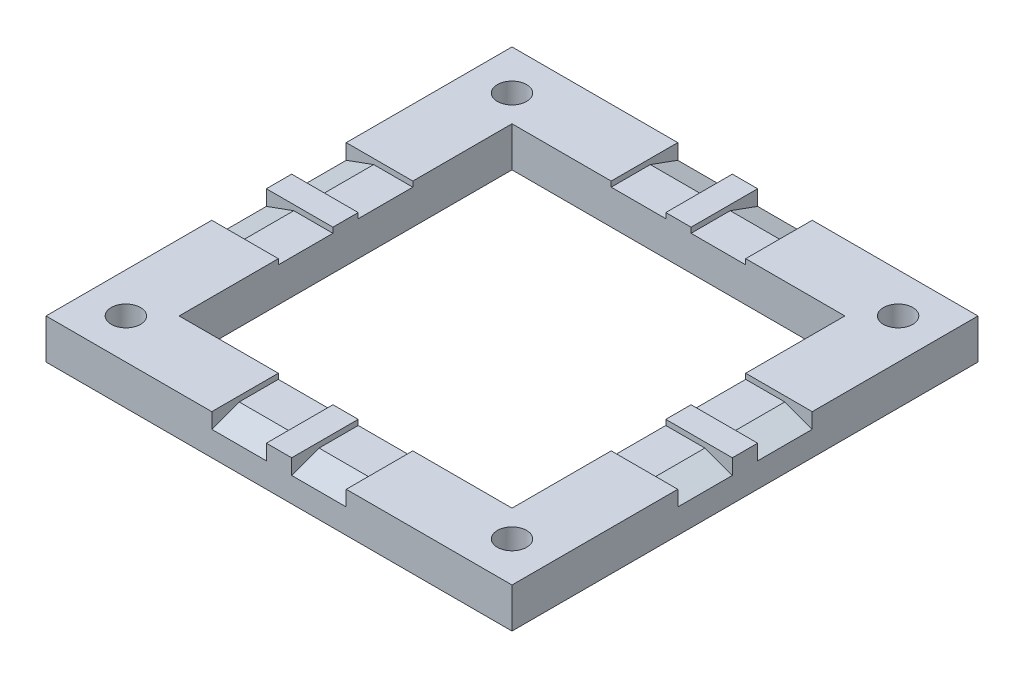
from build123d import *

# Parameters (mm, degrees)
SKETCH1_W             = 35
SKETCH1_H             = 35
BOSS_EXTRUDE1_DEPTH   = 3
SKETCH3_W             = 25
SKETCH3_H             = 25
CUT_EXTRUDE1_DEPTH    = 4
SKETCH4_W             = 5
SKETCH4_H             = 4.1
SKETCH4_W_2           = 4.1
SKETCH4_H_2           = 5
CUT_EXTRUDE2_DEPTH    = 0.4
CHAMFER1_SIZE         = 0.75
CHAMFER1_SIZE2        = 2.060608065
CHAMFER1_PART_2_SIZE  = 0.75
CHAMFER1_PART_2_SIZE2 = 2.060608065
CHAMFER1_PART_3_SIZE  = 0.75
CHAMFER1_PART_3_SIZE2 = 2.060608065
CHAMFER1_PART_4_SIZE  = 0.75
CHAMFER1_PART_4_SIZE2 = 2.060608065
SKETCH6_R             = 1.1
CUT_EXTRUDE5_DEPTH    = 4
CUT_EXTRUDE6_DEPTH    = 1


with BuildPart() as part:
    # Sketch1 → Boss-Extrude1 (new body)
    with BuildSketch(Plane(origin=(0, 0, 0), x_dir=(1, 0, 0), z_dir=(0, 1, 0))):
        Rectangle(SKETCH1_W, SKETCH1_H)
    extrude(amount=BOSS_EXTRUDE1_DEPTH)

    # Sketch3 → Cut-Extrude1 (cut, through all)
    with BuildSketch(Plane(origin=(0, 3, 0), x_dir=(1, 0, 0), z_dir=(0, 1, 0))):
        Rectangle(SKETCH3_W, SKETCH3_H)
    extrude(amount=-CUT_EXTRUDE1_DEPTH, mode=Mode.SUBTRACT)

    # Sketch4 → Cut-Extrude2 (cut)
    with BuildSketch(Plane(origin=(0, 3, 0), x_dir=(1, 0, 0), z_dir=(0, 1, 0))):
        with Locations((-15, 3)):
            Rectangle(SKETCH4_W, SKETCH4_H)
        with Locations((-3, 15)):
            Rectangle(SKETCH4_W_2, SKETCH4_H_2)
        with Locations((3, 15)):
            Rectangle(SKETCH4_W_2, SKETCH4_H_2)
        with Locations((15, 3)):
            Rectangle(SKETCH4_W, SKETCH4_H)
        with Locations((15, -3)):
            Rectangle(SKETCH4_W, SKETCH4_H)
        with Locations((3, -15)):
            Rectangle(SKETCH4_W_2, SKETCH4_H_2)
        with Locations((-3, -15)):
            Rectangle(SKETCH4_W_2, SKETCH4_H_2)
        with Locations((-15, -3)):
            Rectangle(SKETCH4_W, SKETCH4_H)
    extrude(amount=-CUT_EXTRUDE2_DEPTH, mode=Mode.SUBTRACT)

    # Chamfer1
    chamfer1_edges = [part.edges().sort_by_distance(p)[0] for p in [
        (3, 2.6, 17.5),
        (-3, 2.6, 17.5),
    ]]
    chamfer1_side = [part.faces().sort_by_distance(p)[0] for p in [
        (0, 1.458081007, 17.5),
    ]]
    chamfer(chamfer1_edges, length=CHAMFER1_SIZE, length2=CHAMFER1_SIZE2, reference=chamfer1_side[0])

    # Chamfer1 part 2
    chamfer1_part_2_edges = [part.edges().sort_by_distance(p)[0] for p in [
        (-17.5, 2.6, 3),
        (-17.5, 2.6, -3),
    ]]
    chamfer1_part_2_side = [part.faces().sort_by_distance(p)[0] for p in [
        (-17.5, 1.458081007, 0),
    ]]
    chamfer(chamfer1_part_2_edges, length=CHAMFER1_PART_2_SIZE, length2=CHAMFER1_PART_2_SIZE2, reference=chamfer1_part_2_side[0])

    # Chamfer1 part 3
    chamfer1_part_3_edges = [part.edges().sort_by_distance(p)[0] for p in [
        (-3, 2.6, -17.5),
        (3, 2.6, -17.5),
    ]]
    chamfer1_part_3_side = [part.faces().sort_by_distance(p)[0] for p in [
        (0, 1.458081007, -17.5),
    ]]
    chamfer(chamfer1_part_3_edges, length=CHAMFER1_PART_3_SIZE, length2=CHAMFER1_PART_3_SIZE2, reference=chamfer1_part_3_side[0])

    # Chamfer1 part 4
    chamfer1_part_4_edges = [part.edges().sort_by_distance(p)[0] for p in [
        (17.5, 2.6, -3),
        (17.5, 2.6, 3),
    ]]
    chamfer1_part_4_side = [part.faces().sort_by_distance(p)[0] for p in [
        (17.5, 1.458081007, 0),
    ]]
    chamfer(chamfer1_part_4_edges, length=CHAMFER1_PART_4_SIZE, length2=CHAMFER1_PART_4_SIZE2, reference=chamfer1_part_4_side[0])

    # Sketch6 → Cut-Extrude5 (cut, through all)
    with BuildSketch(Plane(origin=(0, 3, 0), x_dir=(1, 0, 0), z_dir=(0, 1, 0))):
        with Locations((14.5, 14.5)):
            Circle(SKETCH6_R)
        with Locations((-14.5, 14.5)):
            Circle(SKETCH6_R)
        with Locations((-14.5, -14.5)):
            Circle(SKETCH6_R)
        with Locations((14.5, -14.5)):
            Circle(SKETCH6_R)
    extrude(amount=-CUT_EXTRUDE5_DEPTH, mode=Mode.SUBTRACT)

    # Sketch7 → Cut-Extrude6 (cut)
    with BuildSketch(Plane.XZ):
        Polygon((-12.867006838, 12.867006838), (-12.269289857, 15.097716981), (-13.902283019, 16.730710143), (-16.132993162, 16.132993162), (-16.730710143, 13.902283019), (-15.097716981, 12.269289857), align=None)
        Polygon((12.867006838, 12.867006838), (15.097716981, 12.269289857), (16.730710143, 13.902283019), (16.132993162, 16.132993162), (13.902283019, 16.730710143), (12.269289857, 15.097716981), align=None)
        Polygon((12.867006838, -12.867006838), (12.269289857, -15.097716981), (13.902283019, -16.730710143), (16.132993162, -16.132993162), (16.730710143, -13.902283019), (15.097716981, -12.269289857), align=None)
        Polygon((-12.867006838, -12.867006838), (-15.097716981, -12.269289857), (-16.730710143, -13.902283019), (-16.132993162, -16.132993162), (-13.902283019, -16.730710143), (-12.269289857, -15.097716981), align=None)
    extrude(amount=-CUT_EXTRUDE6_DEPTH, mode=Mode.SUBTRACT)


solid = part.part
